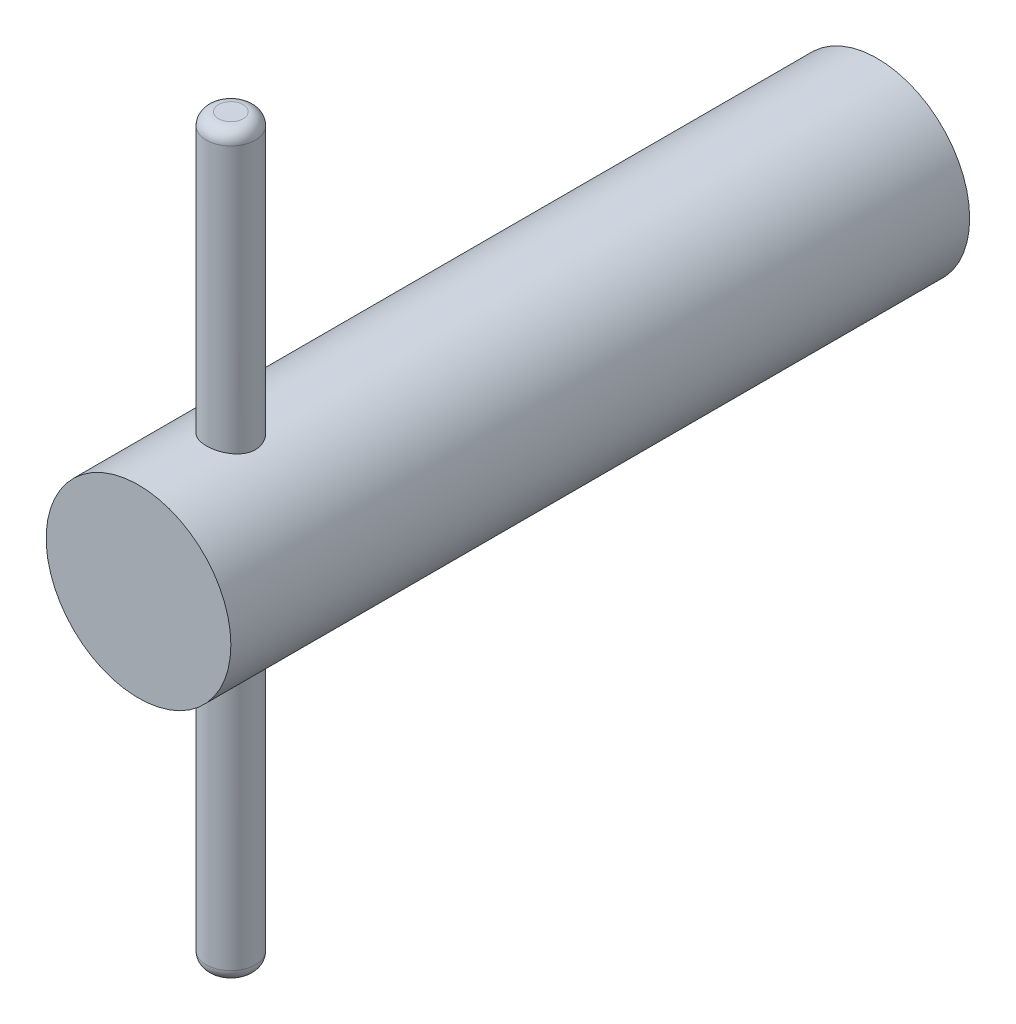
from build123d import *

# Parameters (mm, degrees)
CROQUIS2_R              = 15
SALIENTE_EXTRUIR1_DEPTH = 120
CORTAR_EXTRUIR1_DEPTH   = 50
CROQUIS4_R              = 4
SALIENTE_EXTRUIR2_DEPTH = 60
REDONDEO5_R             = 2


with BuildPart() as part:
    # Croquis2 → Saliente-Extruir1 (new body)
    with BuildSketch(Plane.XY):
        Circle(CROQUIS2_R)
    extrude(amount=SALIENTE_EXTRUIR1_DEPTH)

    # Croquis3 → Cortar-Extruir1 (cut)
    with BuildSketch(Plane(origin=(0, 0, 0), x_dir=(-1, 0, 0), z_dir=(0, 0, -1))):
        Polygon((5.741707523, 10.018289677), (-5.805239602, 9.981609414), (-11.546947124, -0.036680263), (-5.741707523, -10.018289677), (5.805239602, -9.981609414), (11.546947124, 0.036680263), align=None)
    extrude(amount=-CORTAR_EXTRUIR1_DEPTH, mode=Mode.SUBTRACT)

    # Croquis4 → Saliente-Extruir2 (add, symmetric)
    with BuildSketch(Plane(origin=(0, 0, 0), x_dir=(1, 0, 0), z_dir=(0, 1, 0))):
        with Locations((0, -105)):
            Circle(CROQUIS4_R)
    extrude(amount=SALIENTE_EXTRUIR2_DEPTH, both=True)

    # Redondeo5
    redondeo5_edges = [part.edges().sort_by_distance(p)[0] for p in [
        (-4, -60, 105),
        (-4, 60, 105),
    ]]
    fillet(redondeo5_edges, radius=REDONDEO5_R)


solid = part.part
